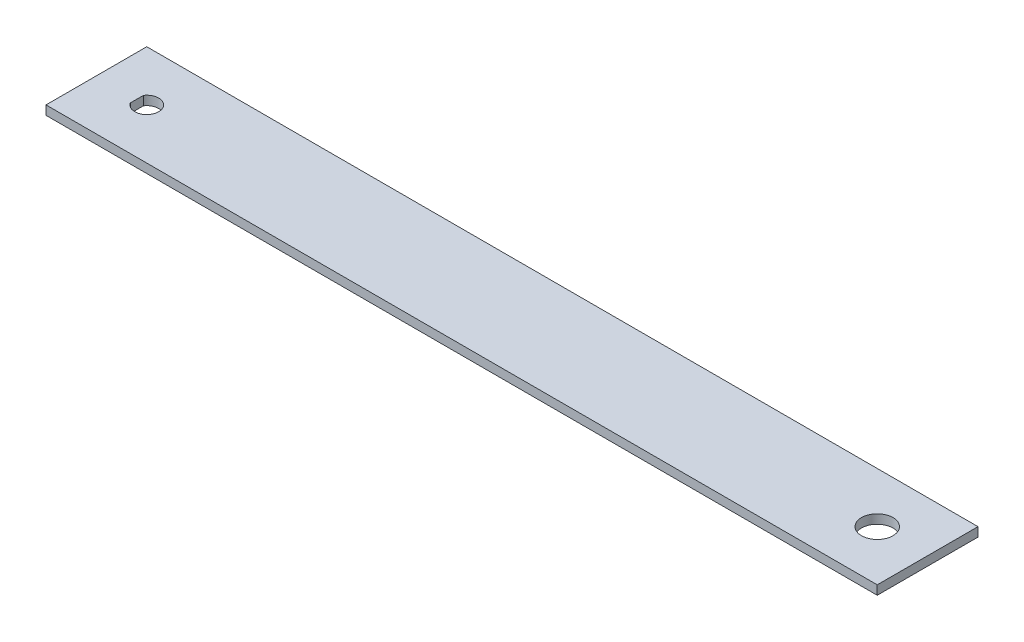
from build123d import *

# Parameters (mm, degrees)
SKETCH1_W           = 209.55
SKETCH1_H           = 25.4
BOSS_EXTRUDE1_DEPTH = 2.286
SKETCH2_R           = 3.96875
CUT_EXTRUDE1_DEPTH  = 3.286


with BuildPart() as part:
    # Sketch1 → Boss-Extrude1 (new body)
    with BuildSketch(Plane(origin=(0, 0, 0), x_dir=(1, 0, 0), z_dir=(0, 1, 0))):
        with Locations((104.775, 12.7)):
            Rectangle(SKETCH1_W, SKETCH1_H)
    extrude(amount=BOSS_EXTRUDE1_DEPTH)

    # Sketch2 → Cut-Extrude1 (cut, through all)
    with BuildSketch(Plane(origin=(0, 2.286, 0), x_dir=(1, 0, 0), z_dir=(0, 1, 0))):
        with Locations((196.85, 12.7)):
            Circle(SKETCH2_R)
        with BuildLine():
            Line((10.2, 14.358312395), (10.2, 11.041687605))
            ThreePointArc((10.2, 11.041687605), (15.7, 12.7), (10.2, 14.358312395))
        make_face()
    extrude(amount=-CUT_EXTRUDE1_DEPTH, mode=Mode.SUBTRACT)


solid = part.part
